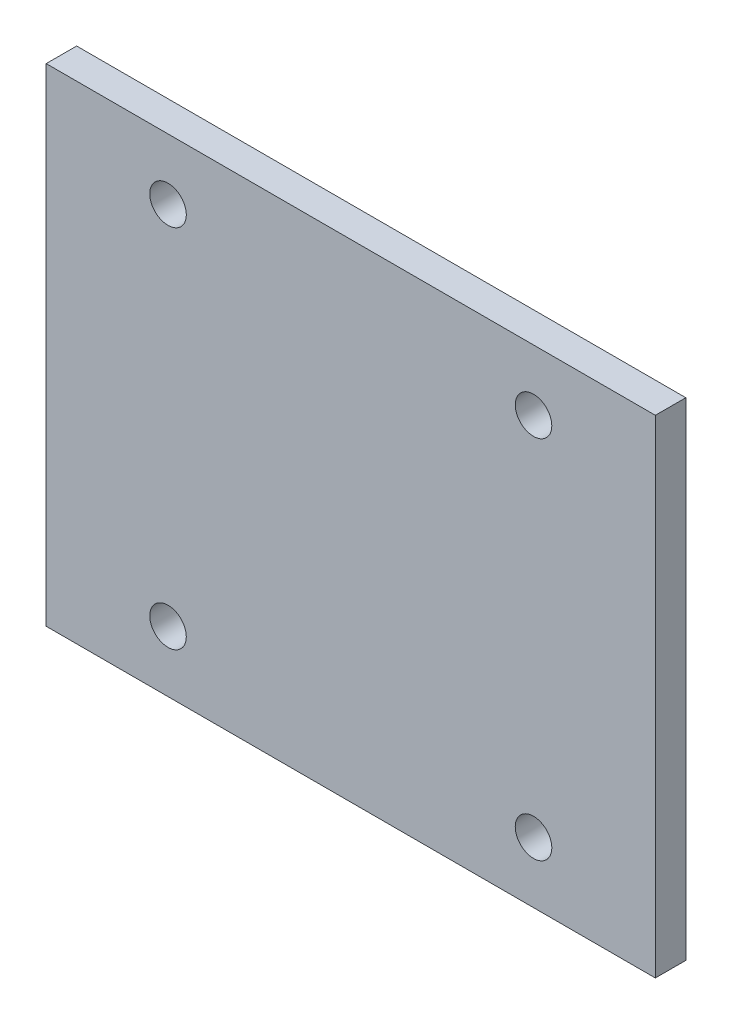
from build123d import *

# Parameters (mm, degrees)
SKETCH1_W           = 50
SKETCH1_H           = 40
BOSS_EXTRUDE1_DEPTH = 2.5
SKETCH2_R           = 1.5
CUT_EXTRUDE1_DEPTH  = 2.5


with BuildPart() as part:
    # Sketch1 → Boss-Extrude1 (new body)
    with BuildSketch(Plane.XY):
        Rectangle(SKETCH1_W, SKETCH1_H)
    extrude(amount=BOSS_EXTRUDE1_DEPTH)

    # Sketch2 → Cut-Extrude1 (cut)
    with BuildSketch(Plane.XY.offset(2.5)):
        with Locations((15, 15)):
            Circle(SKETCH2_R)
        with Locations((15, -15)):
            Circle(SKETCH2_R)
        with Locations((-15, -15)):
            Circle(SKETCH2_R)
        with Locations((-15, 15)):
            Circle(SKETCH2_R)
    extrude(amount=-CUT_EXTRUDE1_DEPTH, mode=Mode.SUBTRACT)


solid = part.part
